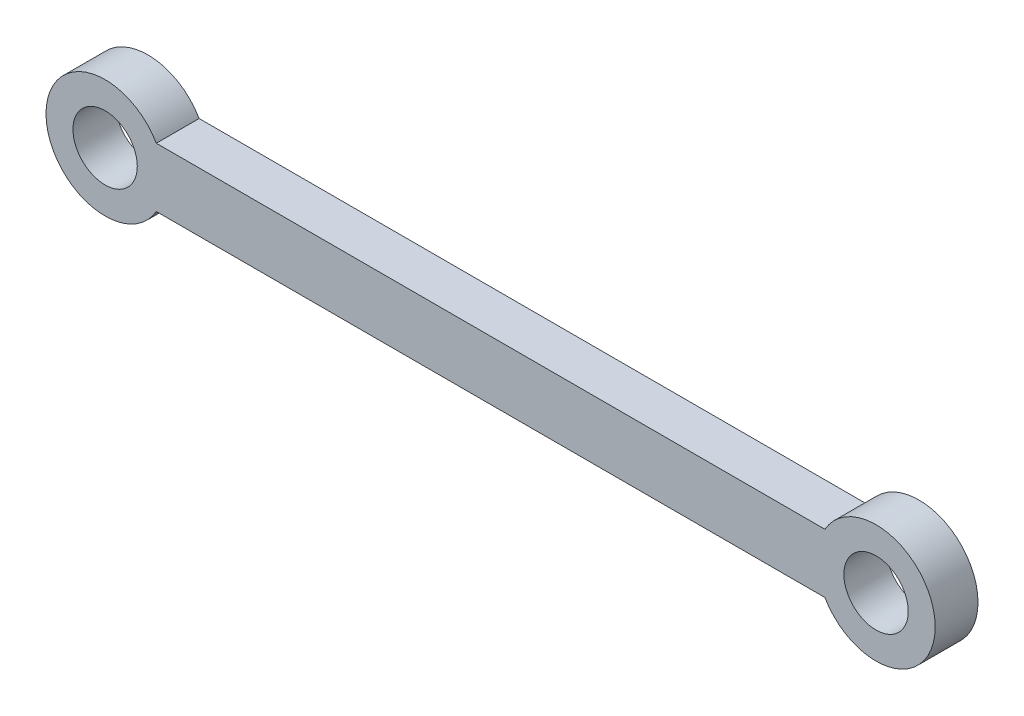
from build123d import *

# Parameters (mm, degrees)
SKETCH1_R           = 3.756461981
BOSS_EXTRUDE1_DEPTH = 5


with BuildPart() as part:
    # Sketch1 → Boss-Extrude1 (new body)
    with BuildSketch(Plane.XY):
        with BuildLine():
            Line((-39.023502664, 3.450532346), (39.023502664, 3.450532346))
            ThreePointArc((39.023502664, 3.450532346), (51.901064691, 0), (39.023502664, -3.450532346))
            Line((39.023502664, -3.450532346), (-39.023502664, -3.450532346))
            ThreePointArc((-39.023502664, -3.450532346), (-51.901064691, 0), (-39.023502664, 3.450532346))
        make_face()
        with Locations((-45, 0)):
            Circle(SKETCH1_R, mode=Mode.SUBTRACT)
        with Locations((45, 0)):
            Circle(SKETCH1_R, mode=Mode.SUBTRACT)
    extrude(amount=BOSS_EXTRUDE1_DEPTH)


solid = part.part
